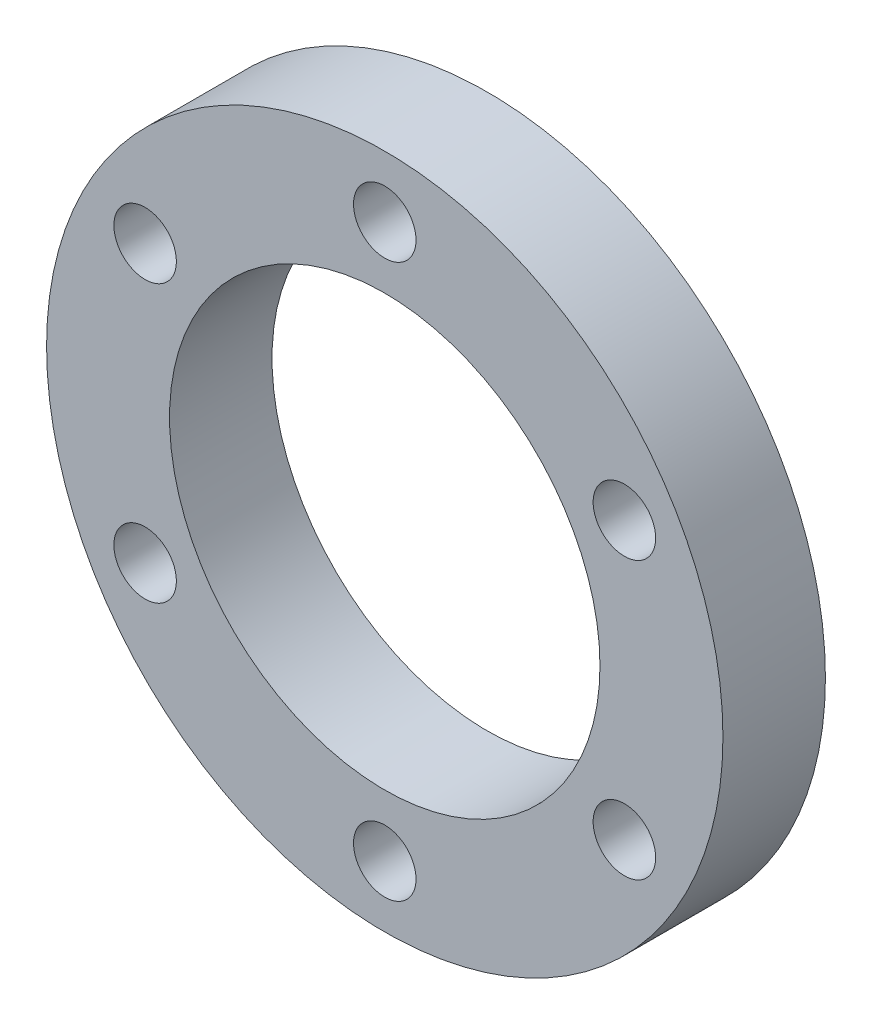
from build123d import *

# Parameters (mm, degrees)
SKETCH_1_R      = 16.5
SKETCH_1_R_2    = 1.525
SKETCH_1_R_3    = 10.5
EXTRUDE_1_DEPTH = 5


with BuildPart() as part:
    # 草图1 → 凸台-拉伸1 (new body)
    with BuildSketch(Plane.XY):
        Circle(SKETCH_1_R)
        with Locations((0, 13.5)):
            Circle(SKETCH_1_R_2, mode=Mode.SUBTRACT)
        with Locations((11.691342951, 6.75)):
            Circle(SKETCH_1_R_2, mode=Mode.SUBTRACT)
        with Locations((11.691342951, -6.75)):
            Circle(SKETCH_1_R_2, mode=Mode.SUBTRACT)
        with Locations((0, -13.5)):
            Circle(SKETCH_1_R_2, mode=Mode.SUBTRACT)
        with Locations((-11.691342951, -6.75)):
            Circle(SKETCH_1_R_2, mode=Mode.SUBTRACT)
        with Locations((-11.691342951, 6.75)):
            Circle(SKETCH_1_R_2, mode=Mode.SUBTRACT)
        Circle(SKETCH_1_R_3, mode=Mode.SUBTRACT)
    extrude(amount=EXTRUDE_1_DEPTH)


solid = part.part
